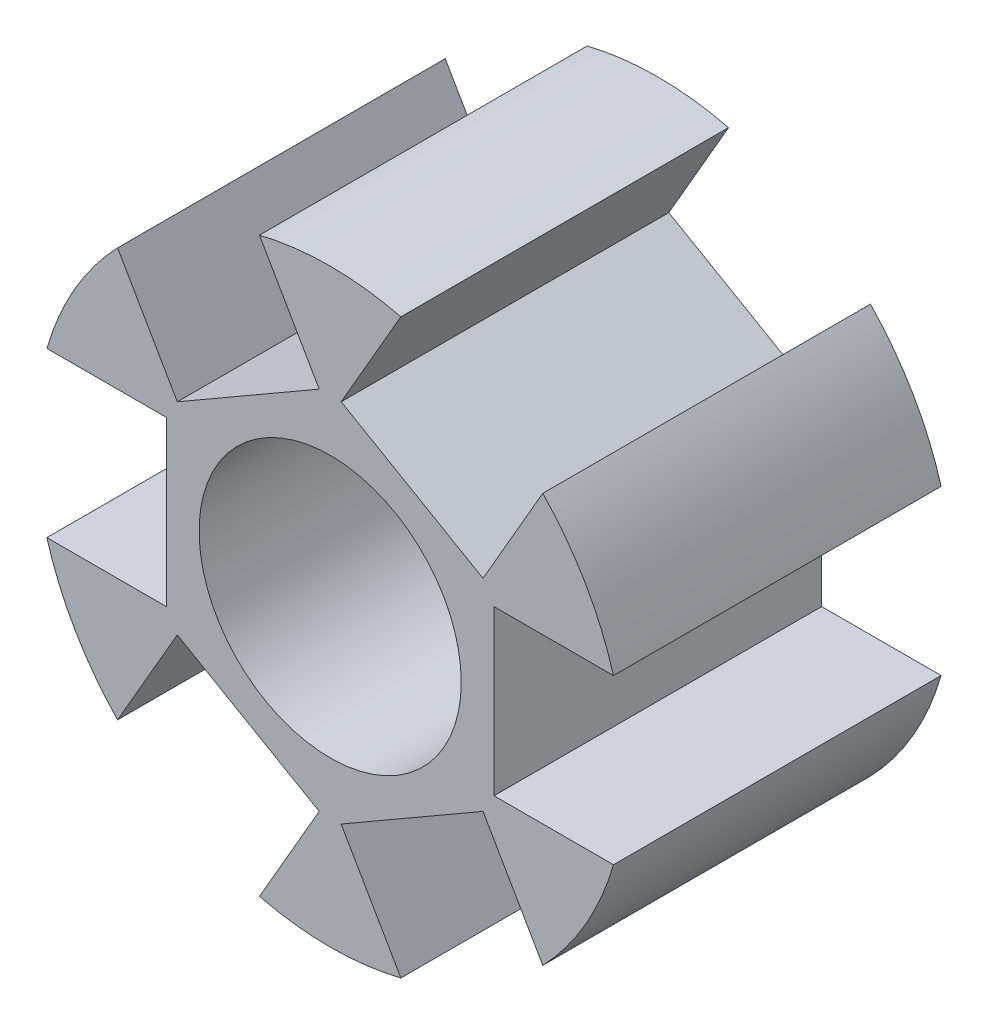
from build123d import *

# Parameters (mm, degrees)
SKETCH1_R           = 9
SKETCH1_R_2         = 4
BOSS_EXTRUDE1_DEPTH = 5
SKETCH2_W           = 5
SKETCH2_H           = 10
CUT_EXTRUDE3_DEPTH  = 4
CIRPATTERN1_COUNT   = 6


with BuildPart() as part:
    # Sketch1 → Boss-Extrude1 (new, symmetric)
    with BuildSketch(Plane.XY):
        Circle(SKETCH1_R)
        Circle(SKETCH1_R_2, mode=Mode.SUBTRACT)
    extrude(amount=BOSS_EXTRUDE1_DEPTH, both=True)

    # Sketch2 → Cut-Extrude3 (cut)
    with BuildSketch(Plane(origin=(-9, -17.193061184, 0), x_dir=(0, -1, 0), z_dir=(1, 0, 0))):
        with Locations((-17.193061184, 0)):
            Rectangle(SKETCH2_W, SKETCH2_H)
    cut_extrude3 = extrude(amount=CUT_EXTRUDE3_DEPTH, mode=Mode.SUBTRACT)

    # CirPattern1: Cut-Extrude3 ×6 about axis
    cirpattern1_axis = Axis((0, 0, 5), (0, 0, 1))
    for i in range(1, CIRPATTERN1_COUNT):
        add(cut_extrude3.rotate(cirpattern1_axis, i * 360 / CIRPATTERN1_COUNT), mode=Mode.SUBTRACT)


solid = part.part
